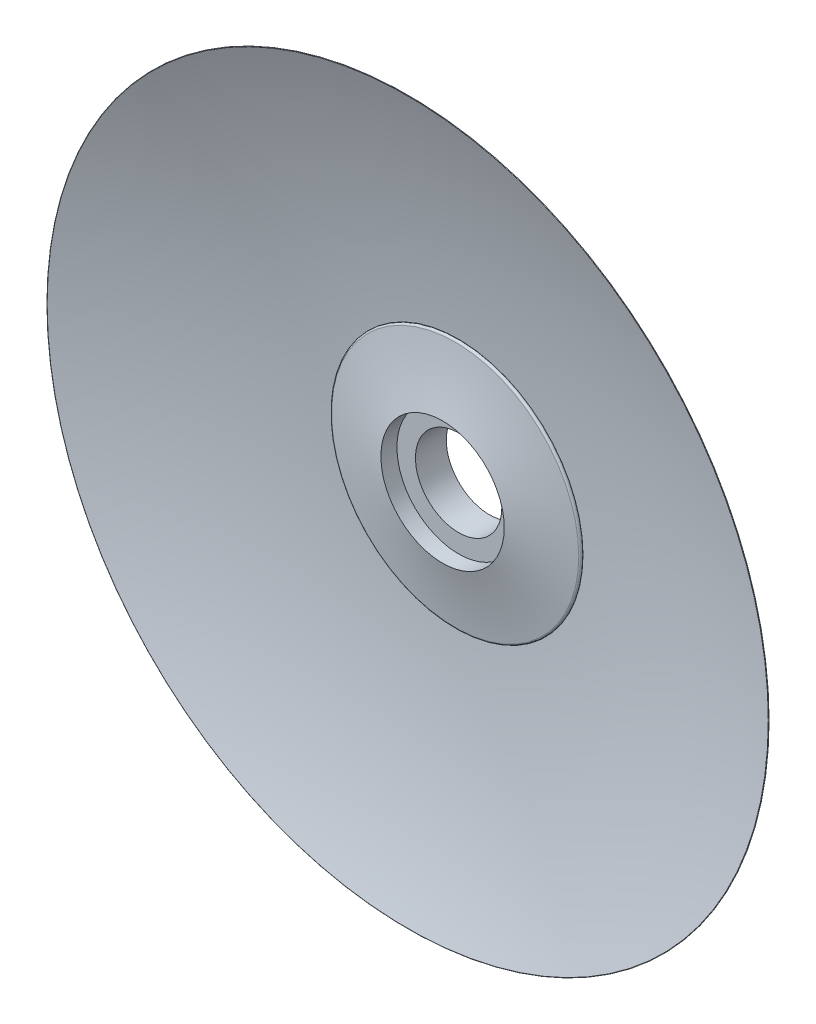
from build123d import *

# Parameters (mm, degrees)
SCALE2_SCALE       = 0.2
SKETCH3_R          = 10
CUT_EXTRUDE1_DEPTH = 65


with BuildPart() as part:
    # Sketch2 → Revolve1 (revolve)
    with BuildSketch(Plane(origin=(0, 0, 0), x_dir=(0, 0, -1), z_dir=(1, 0, 0))):
        with BuildLine():
            Line((-202, 35), (148, 35))
            Line((148, 35), (148, 50))
            ThreePointArc((148, 50), (140.923150734, 90.563910211), (130.62824445, 130.432789199))
            ThreePointArc((130.62824445, 130.432789199), (128.875539156, 131.466229683), (127.70518532, 129.801823789))
            ThreePointArc((127.70518532, 129.801823789), (131.674842705, 89.988642583), (133, 50))
            Line((133, 50), (125, 50))
            ThreePointArc((125, 50), (124.550932144, 75.069769368), (123.204304754, 100.107372942))
            ThreePointArc((123.204304754, 100.107372942), (121.756994731, 101.499204607), (120.222161873, 100.204527125))
            ThreePointArc((120.222161873, 100.204527125), (115.915722567, 74.93843019), (110, 50))
            Line((110, 50), (-202, 50))
            Line((-202, 50), (-202, 35))
        make_face()
    revolve(axis=Axis((0, 0, 0), (0, 0, -1)))

    # Sketch2_4 → Revolve4 (revolve)
    with BuildSketch(Plane(origin=(0, 0, 0), x_dir=(0, 0, -1), z_dir=(1, 0, 0))):
        with BuildLine():
            Line((125, 50), (133, 50))
            ThreePointArc((133, 50), (131.674842705, 89.988642583), (127.70518532, 129.801823789))
            ThreePointArc((127.70518532, 129.801823789), (110.66606555, 212.731553131), (82.199137845, 292.464266858))
            ThreePointArc((82.199137845, 292.464266858), (81.876681496, 292.595776997), (81.735615501, 292.277385103))
            ThreePointArc((81.735615501, 292.277385103), (109.249863185, 197.655425675), (123.204304754, 100.107372942))
            ThreePointArc((123.204304754, 100.107372942), (124.550932144, 75.069769368), (125, 50))
        make_face()
    revolve(axis=Axis((0, 0, 0), (0, 0, -1)))


with BuildPart() as part_1:
    # Scale2: scaled about (0, 0, -55.841199315)
    add(part.part.scale(SCALE2_SCALE).moved(Location((0, 0, -44.672959452))))

    # Sketch3 → Cut-Extrude1 (cut)
    with BuildSketch(Plane.XY.offset(-4.272959452)):
        Circle(SKETCH3_R)
    extrude(amount=-CUT_EXTRUDE1_DEPTH, mode=Mode.SUBTRACT)


solid = part_1.part
